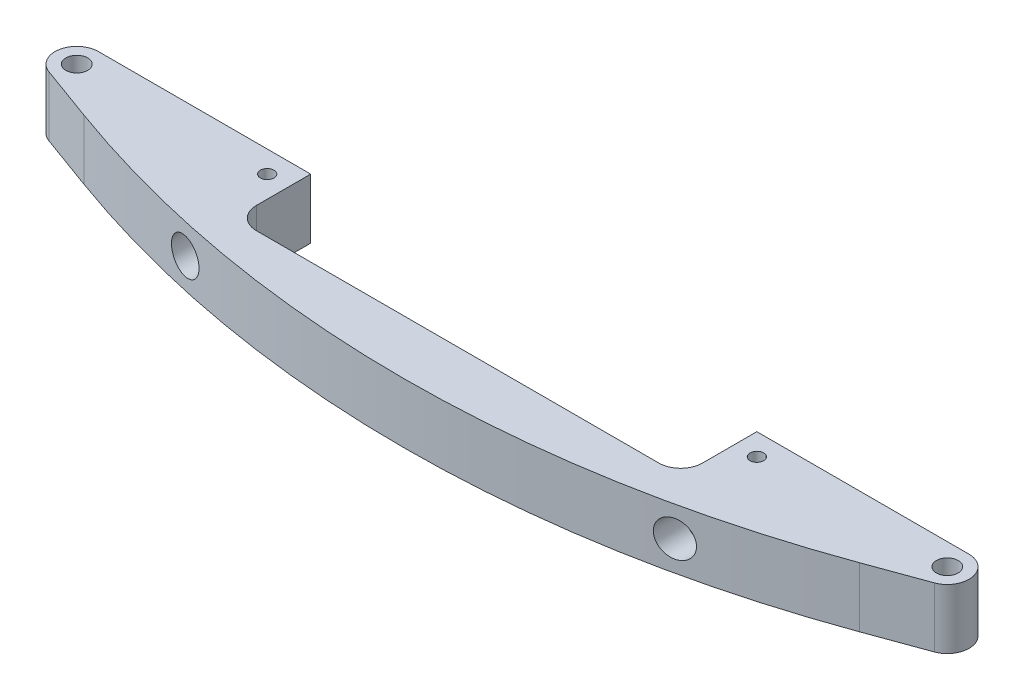
from build123d import *

# Parameters (mm, degrees)
SKIZZE1_R                                            = 2
AUFSATZ_LINEAR_AUSTRAGEN1_DEPTH                      = 5.5
VERRUNDUNG1_R                                        = 4
M3_GEWINDEBOHRUNG1_D                                 = 2.5
STIRNSENKUNG_F_R_M3_ZYLINDERSCHRAUBE_MIT_D           = 3.2
STIRNSENKUNG_F_R_M3_ZYLINDERSCHRAUBE_MIT_CBORE_D     = 6.5
STIRNSENKUNG_F_R_M3_ZYLINDERSCHRAUBE_MIT_CBORE_DEPTH = 10


with BuildPart() as part:
    # Skizze1 → Aufsatz-Linear austragen1 (new body, symmetric)
    with BuildSketch(Plane(origin=(0, 0, 0), x_dir=(1, 0, 0), z_dir=(0, 1, 0))):
        with BuildLine():
            Line((-80, 4), (-45, 4))
            Line((-45, 4), (-41, 4))
            Line((-41, 4), (-41, -10))
            Line((-41, -10), (0, -10))
            Line((0, -10), (0, -20))
            ThreePointArc((0, -20), (-36.187419929, -16.834010994), (-71.275303416, -7.43224095))
            Line((-71.275303416, -7.43224095), (-81.368080573, -3.758770483))
            ThreePointArc((-81.368080573, -3.758770483), (-83.939231012, 0.694592711), (-80, 4))
        make_face()
        with Locations((-80, 0)):
            Circle(SKIZZE1_R, mode=Mode.SUBTRACT)
    extrude(amount=AUFSATZ_LINEAR_AUSTRAGEN1_DEPTH, both=True)

    # Verrundung1
    verrundung1_edges = [part.edges().sort_by_distance(p)[0] for p in [
        (-41, 0, 10),
    ]]
    fillet(verrundung1_edges, radius=VERRUNDUNG1_R)

    # M3 Gewindebohrung1 (through all)
    with Locations(Plane(origin=(0, 5.5, 0), x_dir=(1, 0, 0), z_dir=(0, 1, 0))):
        with Locations((-45, 0)):
            Hole(M3_GEWINDEBOHRUNG1_D / 2)

    # Spiegeln3: part across plane


with BuildPart() as part_1:
    add(part.part)
    add(part.part.mirror(Plane(origin=(0, 0, 0), x_dir=(0, 0, 1), z_dir=(1, 0, 0))))

    # Stirnsenkung für  M3 Zylinderschraube mit Schlitz/Kreuzschlitz1 (through all)
    with Locations(Plane.XY.offset(20)):
        with Locations((-45, 0), (45, 0)):
            CounterBoreHole(STIRNSENKUNG_F_R_M3_ZYLINDERSCHRAUBE_MIT_D / 2, STIRNSENKUNG_F_R_M3_ZYLINDERSCHRAUBE_MIT_CBORE_D / 2, STIRNSENKUNG_F_R_M3_ZYLINDERSCHRAUBE_MIT_CBORE_DEPTH)


solid = part_1.part
